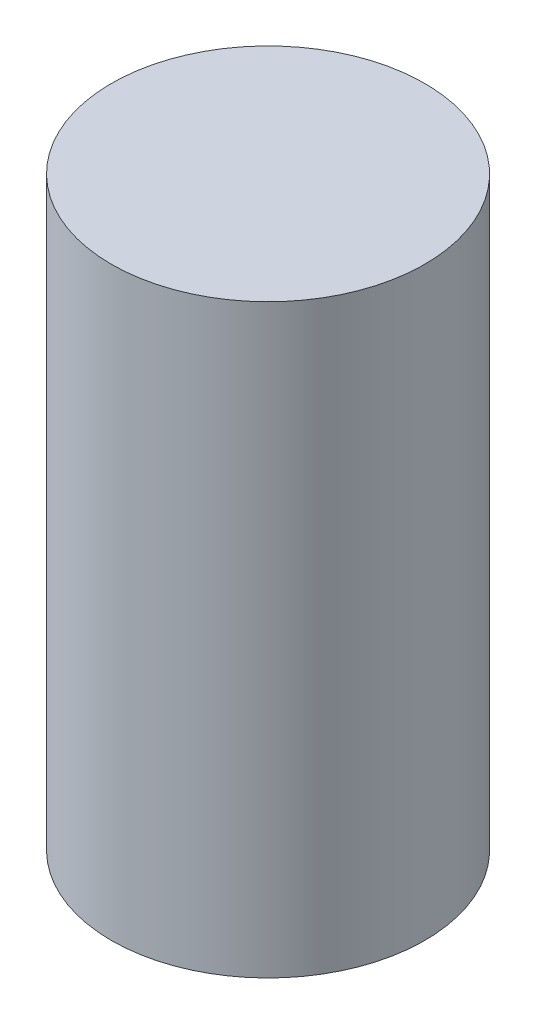
from build123d import *

# Parameters (mm, degrees)
SKETCH1_R           = 2.675
BOSS_EXTRUDE1_DEPTH = 10


with BuildPart() as part:
    # Sketch1 → Boss-Extrude1 (new body)
    with BuildSketch(Plane(origin=(0, 0, 0), x_dir=(1, 0, 0), z_dir=(0, 1, 0))):
        Circle(SKETCH1_R)
    extrude(amount=BOSS_EXTRUDE1_DEPTH)


solid = part.part
